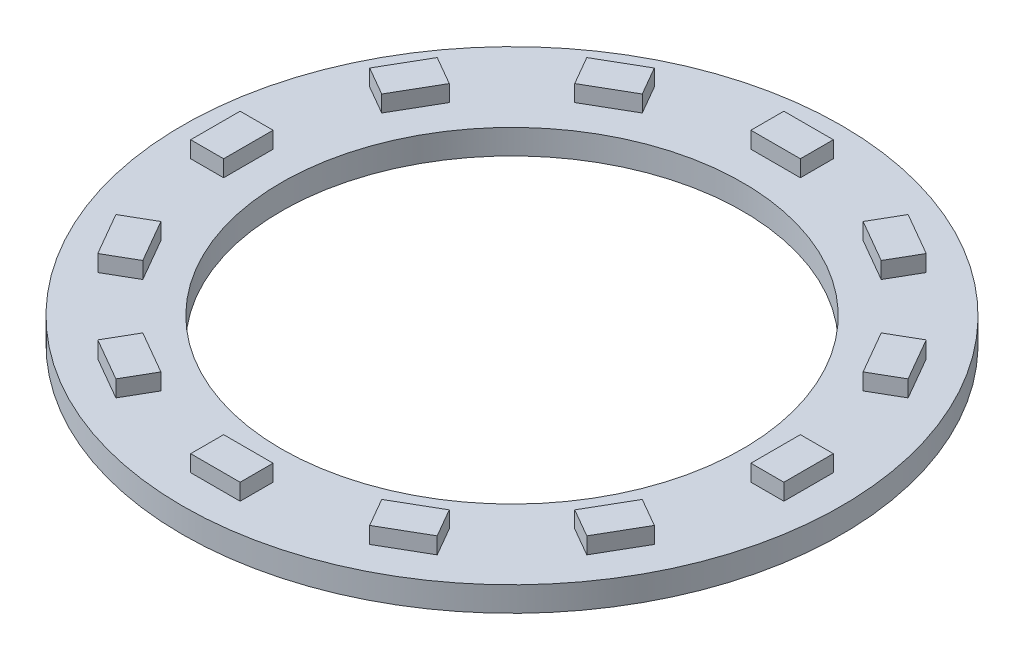
from build123d import *

# Parameters (mm, degrees)
SKETCH1_R           = 20
SKETCH1_R_2         = 14
BOSS_EXTRUDE1_DEPTH = 1.5
SKETCH2_W           = 3
SKETCH2_H           = 2
BOSS_EXTRUDE2_DEPTH = 1
CIRPATTERN1_COUNT   = 12


with BuildPart() as part:
    # Sketch1 → Boss-Extrude1 (new body)
    with BuildSketch(Plane(origin=(0, 0, 0), x_dir=(1, 0, 0), z_dir=(0, 1, 0))):
        Circle(SKETCH1_R)
        Circle(SKETCH1_R_2, mode=Mode.SUBTRACT)
    extrude(amount=BOSS_EXTRUDE1_DEPTH)

    # Sketch2 → Boss-Extrude2 (add)
    with BuildSketch(Plane(origin=(0, 1.5, 0), x_dir=(1, 0, 0), z_dir=(0, 1, 0))):
        with Locations((0, 17)):
            Rectangle(SKETCH2_W, SKETCH2_H)
    boss_extrude2 = extrude(amount=BOSS_EXTRUDE2_DEPTH)

    # CirPattern1: Boss-Extrude2 ×12 about axis
    cirpattern1_axis = Axis((0, 0, 0), (0, 1, 0))
    for i in range(1, CIRPATTERN1_COUNT):
        add(boss_extrude2.rotate(cirpattern1_axis, i * 360 / CIRPATTERN1_COUNT))


solid = part.part
